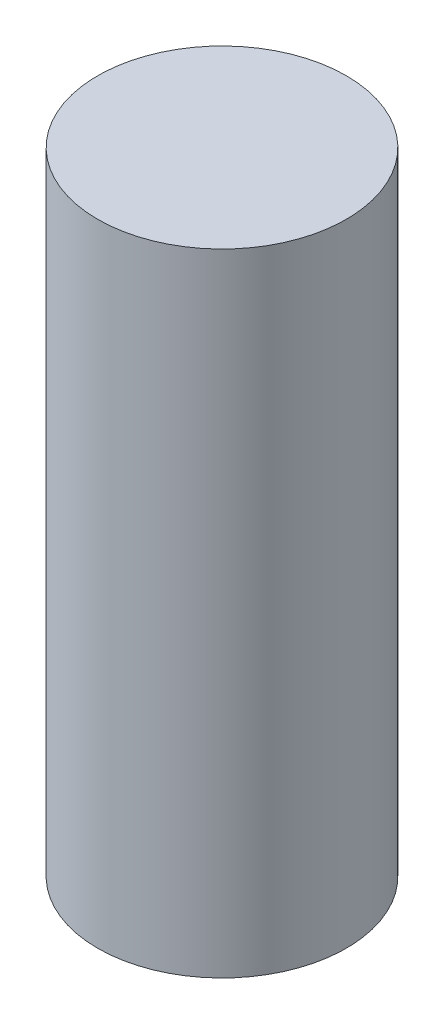
from build123d import *

# Parameters (mm, degrees)
SKETCH1_R                   = 6.35
BOSS_EXTRUDE1_DEPTH         = 22.07514
SKETCH2_R                   = 6.35
BOSS_EXTRUDE2_DEPTH         = 10.16
F_1_4_28_TAPPED_HOLE1_D     = 5.4102
F_1_4_28_TAPPED_HOLE1_DEPTH = 15.494
F_1_4_28_TAPPED_HOLE1_TIP   = 1.625388061
SKETCH5_R                   = 6.35
BOSS_EXTRUDE3_DEPTH         = 3.175


with BuildPart() as part:
    # Sketch1 → Boss-Extrude1 (new body)
    with BuildSketch(Plane(origin=(0, 0, 0), x_dir=(1, 0, 0), z_dir=(0, 1, 0))):
        Circle(SKETCH1_R)
    extrude(amount=BOSS_EXTRUDE1_DEPTH)

    # Sketch2 → Boss-Extrude2 (add)
    with BuildSketch(Plane.XZ):
        Circle(SKETCH2_R)
    extrude(amount=BOSS_EXTRUDE2_DEPTH)

    # 1/4-28 Tapped Hole1
    with Locations(Plane(origin=(0, -10.16, 0), x_dir=(-1, 0, 0), z_dir=(0, -1, 0))):
        with Locations((0, 0)):
            Hole(F_1_4_28_TAPPED_HOLE1_D / 2, depth=F_1_4_28_TAPPED_HOLE1_DEPTH)
            with Locations((0, 0, -(F_1_4_28_TAPPED_HOLE1_DEPTH + F_1_4_28_TAPPED_HOLE1_TIP / 2))):  # 118° drill point
                Cone(0, F_1_4_28_TAPPED_HOLE1_D / 2, F_1_4_28_TAPPED_HOLE1_TIP, mode=Mode.SUBTRACT)

    # Sketch5 → Boss-Extrude3 (add)
    with BuildSketch(Plane(origin=(0, 22.07514, 0), x_dir=(1, 0, 0), z_dir=(0, 1, 0))):
        Circle(SKETCH5_R)
    extrude(amount=-BOSS_EXTRUDE3_DEPTH)


solid = part.part
